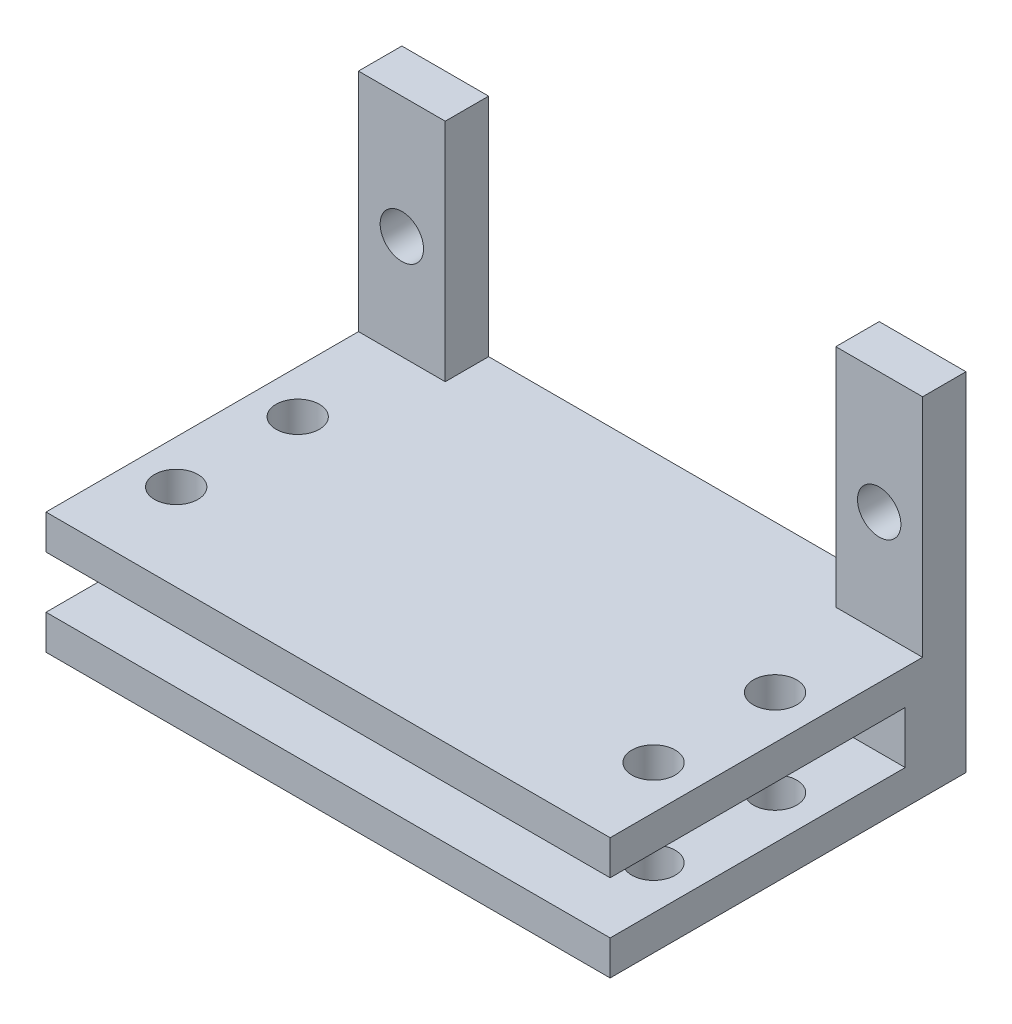
from build123d import *

# Parameters (mm, degrees)
SKETCH1_W               = 5
SKETCH1_H               = 13
SKETCH1_R               = 1.25
BOSS_EXTRUDE1_DEPTH     = 2.5
BOSS_EXTRUDE1_2_DEPTH   = 2.5
SKETCH1_5_W             = 32.5
SKETCH1_5_H             = 2
BOSS_EXTRUDE2_DEPTH     = 20.5
SKETCH1_6_W             = 32.5
SKETCH1_6_H             = 3
BOSS_EXTRUDE3_DEPTH     = 3.5
CUT_EXTRUDE2_DEPTH      = 30.211513141
CUT_EXTRUDE2_DEPTH_BACK = 30.211513141
SKETCH2_R               = 1.25


with BuildPart() as part:
    # Sketch1 → Boss-Extrude1 (new body)
    with BuildSketch(Plane.XY):
        with Locations((-13.75, 6.5)):
            Rectangle(SKETCH1_W, SKETCH1_H)
        with Locations((-13.75, 6)):
            Circle(SKETCH1_R, mode=Mode.SUBTRACT)
    extrude(amount=BOSS_EXTRUDE1_DEPTH)



with BuildPart() as body_2:
    # Sketch1 → Boss-Extrude1 2 (new body)
    with BuildSketch(Plane.XY):
        with Locations((13.75, 6.5)):
            Rectangle(SKETCH1_W, SKETCH1_H)
        with Locations((13.75, 6)):
            Circle(SKETCH1_R, mode=Mode.SUBTRACT)
    extrude(amount=BOSS_EXTRUDE1_2_DEPTH)


with BuildPart() as part_1:
    add(part.part)

    add(body_2.part)  # Boss-Extrude2 merges body 2
    # Sketch1_5 → Boss-Extrude2 (add)
    with BuildSketch(Plane.XY):
        with Locations((0, -1)):
            Rectangle(SKETCH1_5_W, SKETCH1_5_H)
        with Locations((0, -6)):
            Rectangle(SKETCH1_5_W, SKETCH1_5_H)
    extrude(amount=BOSS_EXTRUDE2_DEPTH)

    # Sketch1_6 → Boss-Extrude3 (add)
    with BuildSketch(Plane.XY):
        with Locations((0, -3.5)):
            Rectangle(SKETCH1_6_W, SKETCH1_6_H)
    extrude(amount=BOSS_EXTRUDE3_DEPTH)

    # Sketch2 → Cut-Extrude2 (cut, two sides: drawn at the far end of the back side and taken through both)
    with BuildSketch(Plane(origin=(0, 0, 0), x_dir=(1, 0, 0), z_dir=(0, 1, 0)).offset(-CUT_EXTRUDE2_DEPTH_BACK)):
        with Locations((13.75, -8.5)):
            Circle(SKETCH2_R)
        with Locations((13.75, -15.5)):
            Circle(SKETCH2_R)
        with Locations((-13.75, -15.5)):
            Circle(SKETCH2_R)
        with Locations((-13.75, -8.5)):
            Circle(SKETCH2_R)
    extrude(amount=CUT_EXTRUDE2_DEPTH + CUT_EXTRUDE2_DEPTH_BACK, mode=Mode.SUBTRACT)


solid = part_1.part
